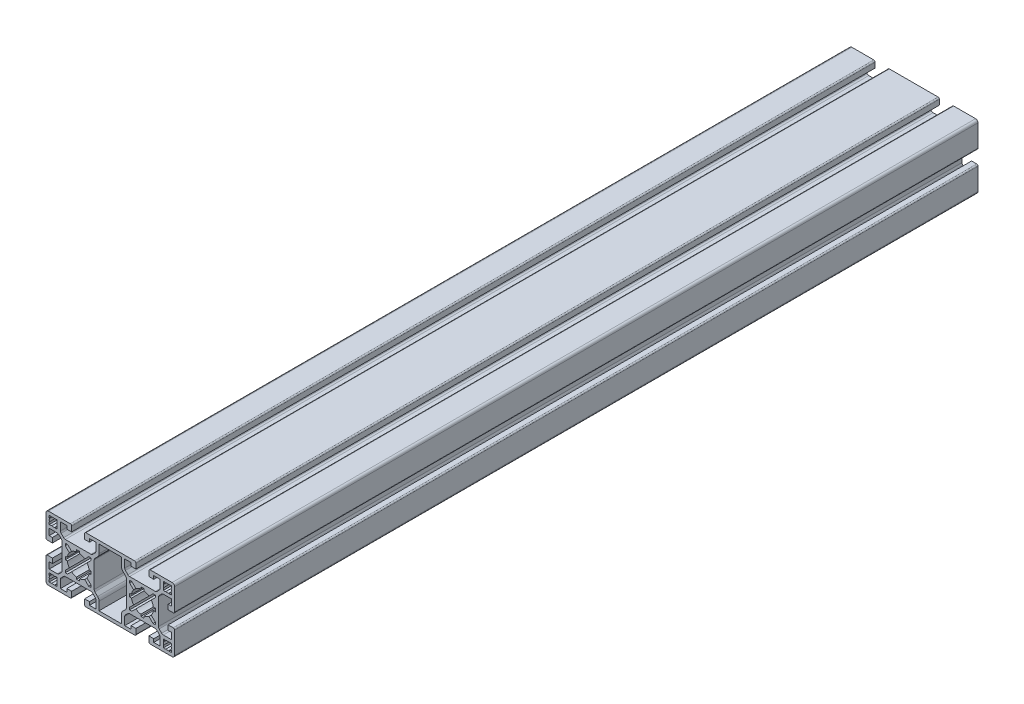
from build123d import *

# Parameters (mm, degrees)
RESSALTO_EXTRUS_O1_DEPTH = 250


with BuildPart() as part:
    # Esboço1 → Ressalto-extrusão1 (new body, symmetric)
    with BuildSketch(Plane.XY):
        with BuildLine():
            Line((-38.5, 20), (-24.85, 20))
            ThreePointArc((-24.85, 20), (-24.284314575, 19.765685425), (-24.05, 19.2))
            Line((-24.05, 19.2), (-24.05, 16))
            Line((-24.05, 16), (-27.05, 16))
            Line((-27.05, 16), (-27.05, 18))
            Line((-27.05, 18), (-31, 18))
            Line((-31, 18), (-31, 13.035533906))
            ThreePointArc((-31, 13.035533906), (-30.885819299, 12.461508757), (-30.560660172, 11.974873734))
            Line((-30.560660172, 11.974873734), (-29.025126266, 10.439339828))
            ThreePointArc((-29.025126266, 10.439339828), (-28.538491243, 10.114180701), (-27.964466094, 10))
            Line((-27.964466094, 10), (-12.035533906, 10))
            ThreePointArc((-12.035533906, 10), (-11.461508757, 10.114180701), (-10.974873734, 10.439339828))
            Line((-10.974873734, 10.439339828), (-9.439339828, 11.974873734))
            ThreePointArc((-9.439339828, 11.974873734), (-9.114180701, 12.461508757), (-9, 13.035533906))
            Line((-9, 13.035533906), (-9, 18))
            Line((-9, 18), (-12.95, 18))
            Line((-12.95, 18), (-12.95, 16))
            Line((-12.95, 16), (-15.95, 16))
            Line((-15.95, 16), (-15.95, 19.2))
            ThreePointArc((-15.95, 19.2), (-15.715685425, 19.765685425), (-15.15, 20))
            Line((-15.15, 20), (15.15, 20))
            ThreePointArc((15.15, 20), (15.715685425, 19.765685425), (15.95, 19.2))
            Line((15.95, 19.2), (15.95, 16))
            Line((15.95, 16), (12.95, 16))
            Line((12.95, 16), (12.95, 18))
            Line((12.95, 18), (9, 18))
            Line((9, 18), (9, 13.035533906))
            ThreePointArc((9, 13.035533906), (9.114180701, 12.461508757), (9.439339828, 11.974873734))
            Line((9.439339828, 11.974873734), (10.974873734, 10.439339828))
            ThreePointArc((10.974873734, 10.439339828), (11.461508757, 10.114180701), (12.035533906, 10))
            Line((12.035533906, 10), (27.964466094, 10))
            ThreePointArc((27.964466094, 10), (28.538491243, 10.114180701), (29.025126266, 10.439339828))
            Line((29.025126266, 10.439339828), (30.560660172, 11.974873734))
            ThreePointArc((30.560660172, 11.974873734), (30.885819299, 12.461508757), (31, 13.035533906))
            Line((31, 13.035533906), (31, 18))
            Line((31, 18), (27.05, 18))
            Line((27.05, 18), (27.05, 16))
            Line((27.05, 16), (24.05, 16))
            Line((24.05, 16), (24.05, 19.2))
            ThreePointArc((24.05, 19.2), (24.284314575, 19.765685425), (24.85, 20))
            Line((24.85, 20), (38.5, 20))
            ThreePointArc((38.5, 20), (39.560660172, 19.560660172), (40, 18.5))
            Line((40, 18.5), (40, 4.85))
            ThreePointArc((40, 4.85), (39.765685425, 4.284314575), (39.2, 4.05))
            Line((39.2, 4.05), (36, 4.05))
            Line((36, 4.05), (36, 7.05))
            Line((36, 7.05), (38, 7.05))
            Line((38, 7.05), (38, 11))
            Line((38, 11), (33.035533906, 11))
            ThreePointArc((33.035533906, 11), (32.461508757, 10.885819299), (31.974873734, 10.560660172))
            Line((31.974873734, 10.560660172), (30.439339828, 9.025126266))
            ThreePointArc((30.439339828, 9.025126266), (30.114180701, 8.538491243), (30, 7.964466094))
            Line((30, 7.964466094), (30, -7.964466094))
            ThreePointArc((30, -7.964466094), (30.114180701, -8.538491243), (30.439339828, -9.025126266))
            Line((30.439339828, -9.025126266), (31.974873734, -10.560660172))
            ThreePointArc((31.974873734, -10.560660172), (32.461508757, -10.885819299), (33.035533906, -11))
            Line((33.035533906, -11), (38, -11))
            Line((38, -11), (38, -7.05))
            Line((38, -7.05), (36, -7.05))
            Line((36, -7.05), (36, -4.05))
            Line((36, -4.05), (39.2, -4.05))
            ThreePointArc((39.2, -4.05), (39.765685425, -4.284314575), (40, -4.85))
            Line((40, -4.85), (40, -18.5))
            ThreePointArc((40, -18.5), (39.560660172, -19.560660172), (38.5, -20))
            Line((38.5, -20), (24.85, -20))
            ThreePointArc((24.85, -20), (24.284314575, -19.765685425), (24.05, -19.2))
            Line((24.05, -19.2), (24.05, -16))
            Line((24.05, -16), (27.05, -16))
            Line((27.05, -16), (27.05, -18))
            Line((27.05, -18), (31, -18))
            Line((31, -18), (31, -13.035533906))
            ThreePointArc((31, -13.035533906), (30.885819299, -12.461508757), (30.560660172, -11.974873734))
            Line((30.560660172, -11.974873734), (29.025126266, -10.439339828))
            ThreePointArc((29.025126266, -10.439339828), (28.538491243, -10.114180701), (27.964466094, -10))
            Line((27.964466094, -10), (12.035533906, -10))
            ThreePointArc((12.035533906, -10), (11.461508757, -10.114180701), (10.974873734, -10.439339828))
            Line((10.974873734, -10.439339828), (9.439339828, -11.974873734))
            ThreePointArc((9.439339828, -11.974873734), (9.114180701, -12.461508757), (9, -13.035533906))
            Line((9, -13.035533906), (9, -18))
            Line((9, -18), (12.95, -18))
            Line((12.95, -18), (12.95, -16))
            Line((12.95, -16), (15.95, -16))
            Line((15.95, -16), (15.95, -19.2))
            ThreePointArc((15.95, -19.2), (15.715685425, -19.765685425), (15.15, -20))
            Line((15.15, -20), (-15.15, -20))
            ThreePointArc((-15.15, -20), (-15.715685425, -19.765685425), (-15.95, -19.2))
            Line((-15.95, -19.2), (-15.95, -16))
            Line((-15.95, -16), (-12.95, -16))
            Line((-12.95, -16), (-12.95, -18))
            Line((-12.95, -18), (-9, -18))
            Line((-9, -18), (-9, -13.035533906))
            ThreePointArc((-9, -13.035533906), (-9.114180701, -12.461508757), (-9.439339828, -11.974873734))
            Line((-9.439339828, -11.974873734), (-10.974873734, -10.439339828))
            ThreePointArc((-10.974873734, -10.439339828), (-11.461508757, -10.114180701), (-12.035533906, -10))
            Line((-12.035533906, -10), (-27.964466094, -10))
            ThreePointArc((-27.964466094, -10), (-28.538491243, -10.114180701), (-29.025126266, -10.439339828))
            Line((-29.025126266, -10.439339828), (-30.560660172, -11.974873734))
            ThreePointArc((-30.560660172, -11.974873734), (-30.885819299, -12.461508757), (-31, -13.035533906))
            Line((-31, -13.035533906), (-31, -18))
            Line((-31, -18), (-27.05, -18))
            Line((-27.05, -18), (-27.05, -16))
            Line((-27.05, -16), (-24.05, -16))
            Line((-24.05, -16), (-24.05, -19.2))
            ThreePointArc((-24.05, -19.2), (-24.284314575, -19.765685425), (-24.85, -20))
            Line((-24.85, -20), (-38.5, -20))
            ThreePointArc((-38.5, -20), (-39.560660172, -19.560660172), (-40, -18.5))
            Line((-40, -18.5), (-40, -4.85))
            ThreePointArc((-40, -4.85), (-39.765685425, -4.284314575), (-39.2, -4.05))
            Line((-39.2, -4.05), (-36, -4.05))
            Line((-36, -4.05), (-36, -7.05))
            Line((-36, -7.05), (-38, -7.05))
            Line((-38, -7.05), (-38, -11))
            Line((-38, -11), (-33.035533906, -11))
            ThreePointArc((-33.035533906, -11), (-32.461508757, -10.885819299), (-31.974873734, -10.560660172))
            Line((-31.974873734, -10.560660172), (-30.439339828, -9.025126266))
            ThreePointArc((-30.439339828, -9.025126266), (-30.114180701, -8.538491243), (-30, -7.964466094))
            Line((-30, -7.964466094), (-30, 7.964466094))
            ThreePointArc((-30, 7.964466094), (-30.114180701, 8.538491243), (-30.439339828, 9.025126266))
            Line((-30.439339828, 9.025126266), (-31.974873734, 10.560660172))
            ThreePointArc((-31.974873734, 10.560660172), (-32.461508757, 10.885819299), (-33.035533906, 11))
            Line((-33.035533906, 11), (-38, 11))
            Line((-38, 11), (-38, 7.05))
            Line((-38, 7.05), (-36, 7.05))
            Line((-36, 7.05), (-36, 4.05))
            Line((-36, 4.05), (-39.2, 4.05))
            ThreePointArc((-39.2, 4.05), (-39.765685425, 4.284314575), (-40, 4.85))
            Line((-40, 4.85), (-40, 18.5))
            ThreePointArc((-40, 18.5), (-39.560660172, 19.560660172), (-38.5, 20))
        make_face()
        with BuildLine():
            Line((-33, 18), (-33, 16.585786438))
            Line((-33, 16.585786438), (-33.172708044, 16.413078393))
            ThreePointArc((-33.172708044, 16.413078393), (-33, 15.5), (-33.172708044, 14.586921606))
            Line((-33.172708044, 14.586921606), (-33, 14.414213562))
            Line((-33, 14.414213562), (-33, 13))
            Line((-33, 13), (-34.414213562, 13))
            Line((-34.414213562, 13), (-34.586921607, 13.172708044))
            ThreePointArc((-34.586921607, 13.172708044), (-35.5, 13), (-36.413078394, 13.172708044))
            Line((-36.413078394, 13.172708044), (-36.585786438, 13))
            Line((-36.585786438, 13), (-38, 13))
            Line((-38, 13), (-38, 14.414213562))
            Line((-38, 14.414213562), (-37.827291956, 14.586921606))
            ThreePointArc((-37.827291956, 14.586921606), (-38, 15.5), (-37.827291956, 16.413078394))
            Line((-37.827291956, 16.413078394), (-38, 16.585786438))
            Line((-38, 16.585786438), (-38, 18))
            Line((-38, 18), (-36.585786438, 18))
            Line((-36.585786438, 18), (-36.413078393, 17.827291956))
            ThreePointArc((-36.413078393, 17.827291956), (-35.5, 18), (-34.586921606, 17.827291956))
            Line((-34.586921606, 17.827291956), (-34.414213562, 18))
            Line((-34.414213562, 18), (-33, 18))
        make_face(mode=Mode.SUBTRACT)
        with BuildLine():
            Line((-28, 6.585786438), (-25.498896635, 4.084683072))
            ThreePointArc((-25.498896635, 4.084683072), (-26.328574798, 2.621381512), (-26.776614199, 1))
            Line((-26.776614199, 1), (-28, 1))
            Line((-28, 1), (-28, -1))
            Line((-28, -1), (-26.776614199, -1))
            ThreePointArc((-26.776614199, -1), (-26.328574798, -2.621381512), (-25.498896635, -4.084683072))
            Line((-25.498896635, -4.084683072), (-28, -6.585786438))
            Line((-28, -6.585786438), (-28, -8))
            Line((-28, -8), (-26.585786438, -8))
            Line((-26.585786438, -8), (-24.084683072, -5.498896635))
            ThreePointArc((-24.084683072, -5.498896635), (-22.621381512, -6.328574798), (-21, -6.776614199))
            Line((-21, -6.776614199), (-21, -8))
            Line((-21, -8), (-19, -8))
            Line((-19, -8), (-19, -6.776614199))
            ThreePointArc((-19, -6.776614199), (-17.378618488, -6.328574798), (-15.915316928, -5.498896635))
            Line((-15.915316928, -5.498896635), (-13.414213562, -8))
            Line((-13.414213562, -8), (-12, -8))
            Line((-12, -8), (-12, -6.585786438))
            Line((-12, -6.585786438), (-14.501103365, -4.084683072))
            ThreePointArc((-14.501103365, -4.084683072), (-13.671425202, -2.621381512), (-13.223385801, -1))
            Line((-13.223385801, -1), (-12, -1))
            Line((-12, -1), (-12, 1))
            Line((-12, 1), (-13.223385801, 1))
            ThreePointArc((-13.223385801, 1), (-13.671425202, 2.621381512), (-14.501103365, 4.084683072))
            Line((-14.501103365, 4.084683072), (-12, 6.585786438))
            Line((-12, 6.585786438), (-12, 8))
            Line((-12, 8), (-13.414213562, 8))
            Line((-13.414213562, 8), (-15.915316928, 5.498896635))
            ThreePointArc((-15.915316928, 5.498896635), (-17.378618488, 6.328574798), (-19, 6.776614199))
            Line((-19, 6.776614199), (-19, 8))
            Line((-19, 8), (-21, 8))
            Line((-21, 8), (-21, 6.776614199))
            ThreePointArc((-21, 6.776614199), (-22.621381512, 6.328574798), (-24.084683072, 5.498896635))
            Line((-24.084683072, 5.498896635), (-26.585786438, 8))
            Line((-26.585786438, 8), (-28, 8))
            Line((-28, 8), (-28, 6.585786438))
        make_face(mode=Mode.SUBTRACT)
        with BuildLine():
            Line((-38, -14.414213562), (-37.827291956, -14.586921606))
            ThreePointArc((-37.827291956, -14.586921606), (-38, -15.5), (-37.827291956, -16.413078394))
            Line((-37.827291956, -16.413078394), (-38, -16.585786438))
            Line((-38, -16.585786438), (-38, -18))
            Line((-38, -18), (-36.585786438, -18))
            Line((-36.585786438, -18), (-36.413078393, -17.827291956))
            ThreePointArc((-36.413078393, -17.827291956), (-35.5, -18), (-34.586921606, -17.827291956))
            Line((-34.586921606, -17.827291956), (-34.414213562, -18))
            Line((-34.414213562, -18), (-33, -18))
            Line((-33, -18), (-33, -16.585786438))
            Line((-33, -16.585786438), (-33.172708044, -16.413078393))
            ThreePointArc((-33.172708044, -16.413078393), (-33, -15.5), (-33.172708044, -14.586921606))
            Line((-33.172708044, -14.586921606), (-33, -14.414213562))
            Line((-33, -14.414213562), (-33, -13))
            Line((-33, -13), (-34.414213562, -13))
            Line((-34.414213562, -13), (-34.586921607, -13.172708044))
            ThreePointArc((-34.586921607, -13.172708044), (-35.5, -13), (-36.413078394, -13.172708044))
            Line((-36.413078394, -13.172708044), (-36.585786438, -13))
            Line((-36.585786438, -13), (-38, -13))
            Line((-38, -13), (-38, -14.414213562))
        make_face(mode=Mode.SUBTRACT)
        with BuildLine():
            Line((-7, 18), (-7, 12.828427125))
            ThreePointArc((-7, 12.828427125), (-7.228361402, 11.680376828), (-7.878679656, 10.707106781))
            Line((-7.878679656, 10.707106781), (-9.560660172, 9.025126266))
            ThreePointArc((-9.560660172, 9.025126266), (-9.885819299, 8.538491243), (-10, 7.964466094))
            Line((-10, 7.964466094), (-10, -7.964466094))
            ThreePointArc((-10, -7.964466094), (-9.885819299, -8.538491243), (-9.560660172, -9.025126266))
            Line((-9.560660172, -9.025126266), (-7.878679656, -10.707106781))
            ThreePointArc((-7.878679656, -10.707106781), (-7.228361402, -11.680376828), (-7, -12.828427125))
            Line((-7, -12.828427125), (-7, -18))
            Line((-7, -18), (7, -18))
            Line((7, -18), (7, -12.828427125))
            ThreePointArc((7, -12.828427125), (7.228361402, -11.680376828), (7.878679656, -10.707106781))
            Line((7.878679656, -10.707106781), (9.560660172, -9.025126266))
            ThreePointArc((9.560660172, -9.025126266), (9.885819299, -8.538491243), (10, -7.964466094))
            Line((10, -7.964466094), (10, 7.964466094))
            ThreePointArc((10, 7.964466094), (9.885819299, 8.538491243), (9.560660172, 9.025126266))
            Line((9.560660172, 9.025126266), (7.878679656, 10.707106781))
            ThreePointArc((7.878679656, 10.707106781), (7.228361402, 11.680376828), (7, 12.828427125))
            Line((7, 12.828427125), (7, 18))
            Line((7, 18), (-7, 18))
        make_face(mode=Mode.SUBTRACT)
        with BuildLine():
            Line((38, 14.414213562), (37.827291956, 14.586921606))
            ThreePointArc((37.827291956, 14.586921606), (38, 15.5), (37.827291956, 16.413078394))
            Line((37.827291956, 16.413078394), (38, 16.585786438))
            Line((38, 16.585786438), (38, 18))
            Line((38, 18), (36.585786438, 18))
            Line((36.585786438, 18), (36.413078393, 17.827291956))
            ThreePointArc((36.413078393, 17.827291956), (35.5, 18), (34.586921606, 17.827291956))
            Line((34.586921606, 17.827291956), (34.414213562, 18))
            Line((34.414213562, 18), (33, 18))
            Line((33, 18), (33, 16.585786438))
            Line((33, 16.585786438), (33.172708044, 16.413078393))
            ThreePointArc((33.172708044, 16.413078393), (33, 15.5), (33.172708044, 14.586921606))
            Line((33.172708044, 14.586921606), (33, 14.414213562))
            Line((33, 14.414213562), (33, 13))
            Line((33, 13), (34.414213562, 13))
            Line((34.414213562, 13), (34.586921607, 13.172708044))
            ThreePointArc((34.586921607, 13.172708044), (35.5, 13), (36.413078394, 13.172708044))
            Line((36.413078394, 13.172708044), (36.585786438, 13))
            Line((36.585786438, 13), (38, 13))
            Line((38, 13), (38, 14.414213562))
        make_face(mode=Mode.SUBTRACT)
        with BuildLine():
            Line((28, 1), (26.776614199, 1))
            ThreePointArc((26.776614199, 1), (26.328574798, 2.621381512), (25.498896635, 4.084683072))
            Line((25.498896635, 4.084683072), (28, 6.585786438))
            Line((28, 6.585786438), (28, 8))
            Line((28, 8), (26.585786438, 8))
            Line((26.585786438, 8), (24.084683072, 5.498896635))
            ThreePointArc((24.084683072, 5.498896635), (22.621381512, 6.328574798), (21, 6.776614199))
            Line((21, 6.776614199), (21, 8))
            Line((21, 8), (19, 8))
            Line((19, 8), (19, 6.776614199))
            ThreePointArc((19, 6.776614199), (17.378618488, 6.328574798), (15.915316928, 5.498896635))
            Line((15.915316928, 5.498896635), (13.414213562, 8))
            Line((13.414213562, 8), (12, 8))
            Line((12, 8), (12, 6.585786438))
            Line((12, 6.585786438), (14.501103365, 4.084683072))
            ThreePointArc((14.501103365, 4.084683072), (13.671425202, 2.621381512), (13.223385801, 1))
            Line((13.223385801, 1), (12, 1))
            Line((12, 1), (12, -1))
            Line((12, -1), (13.223385801, -1))
            ThreePointArc((13.223385801, -1), (13.671425202, -2.621381512), (14.501103365, -4.084683072))
            Line((14.501103365, -4.084683072), (12, -6.585786438))
            Line((12, -6.585786438), (12, -8))
            Line((12, -8), (13.414213562, -8))
            Line((13.414213562, -8), (15.915316928, -5.498896635))
            ThreePointArc((15.915316928, -5.498896635), (17.378618488, -6.328574798), (19, -6.776614199))
            Line((19, -6.776614199), (19, -8))
            Line((19, -8), (21, -8))
            Line((21, -8), (21, -6.776614199))
            ThreePointArc((21, -6.776614199), (22.621381512, -6.328574798), (24.084683072, -5.498896635))
            Line((24.084683072, -5.498896635), (26.585786438, -8))
            Line((26.585786438, -8), (28, -8))
            Line((28, -8), (28, -6.585786438))
            Line((28, -6.585786438), (25.498896635, -4.084683072))
            ThreePointArc((25.498896635, -4.084683072), (26.328574798, -2.621381512), (26.776614199, -1))
            Line((26.776614199, -1), (28, -1))
            Line((28, -1), (28, 1))
        make_face(mode=Mode.SUBTRACT)
        with BuildLine():
            Line((33, -18), (33, -16.585786438))
            Line((33, -16.585786438), (33.172708044, -16.413078393))
            ThreePointArc((33.172708044, -16.413078393), (33, -15.5), (33.172708044, -14.586921606))
            Line((33.172708044, -14.586921606), (33, -14.414213562))
            Line((33, -14.414213562), (33, -13))
            Line((33, -13), (34.414213562, -13))
            Line((34.414213562, -13), (34.586921607, -13.172708044))
            ThreePointArc((34.586921607, -13.172708044), (35.5, -13), (36.413078394, -13.172708044))
            Line((36.413078394, -13.172708044), (36.585786438, -13))
            Line((36.585786438, -13), (38, -13))
            Line((38, -13), (38, -14.414213562))
            Line((38, -14.414213562), (37.827291956, -14.586921606))
            ThreePointArc((37.827291956, -14.586921606), (38, -15.5), (37.827291956, -16.413078394))
            Line((37.827291956, -16.413078394), (38, -16.585786438))
            Line((38, -16.585786438), (38, -18))
            Line((38, -18), (36.585786438, -18))
            Line((36.585786438, -18), (36.413078393, -17.827291956))
            ThreePointArc((36.413078393, -17.827291956), (35.5, -18), (34.586921606, -17.827291956))
            Line((34.586921606, -17.827291956), (34.414213562, -18))
            Line((34.414213562, -18), (33, -18))
        make_face(mode=Mode.SUBTRACT)
    extrude(amount=RESSALTO_EXTRUS_O1_DEPTH, both=True)


solid = part.part
